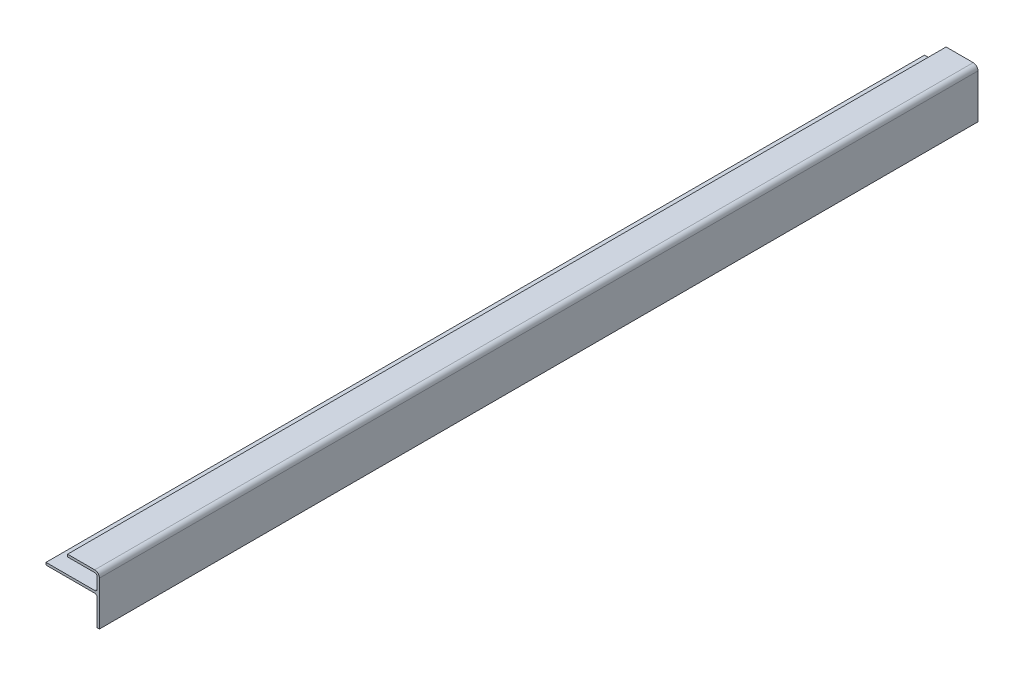
from build123d import *

# Parameters (mm, degrees)
EXTRUDE1_DEPTH = 292.1


with BuildPart() as part:
    # Sketch1 → Extrude1 (new body, symmetric)
    with BuildSketch(Plane.XY):
        with BuildLine():
            Line((1219.2, 19.05), (1219.2, 36.5125))
            ThreePointArc((1219.2, 36.5125), (1218.735032015, 37.635032015), (1217.6125, 38.1))
            Line((1217.6125, 38.1), (1185.2275, 38.1))
            Line((1185.2275, 38.1), (1185.2275, 39.6875))
            Line((1185.2275, 39.6875), (1217.6125, 39.6875))
            ThreePointArc((1217.6125, 39.6875), (1218.735032015, 40.152467985), (1219.2, 41.275))
            Line((1219.2, 41.275), (1219.2, 48.387))
            ThreePointArc((1219.2, 48.387), (1218.735032015, 49.509532015), (1217.6125, 49.9745))
            Line((1217.6125, 49.9745), (1199.5785, 49.9745))
            Line((1199.5785, 49.9745), (1199.5785, 51.562))
            Line((1199.5785, 51.562), (1217.6125, 51.562))
            ThreePointArc((1217.6125, 51.562), (1219.85756403, 50.63206403), (1220.7875, 48.387))
            Line((1220.7875, 48.387), (1220.7875, 19.05))
            Line((1220.7875, 19.05), (1219.2, 19.05))
        make_face()
    extrude(amount=EXTRUDE1_DEPTH, both=True)


solid = part.part
